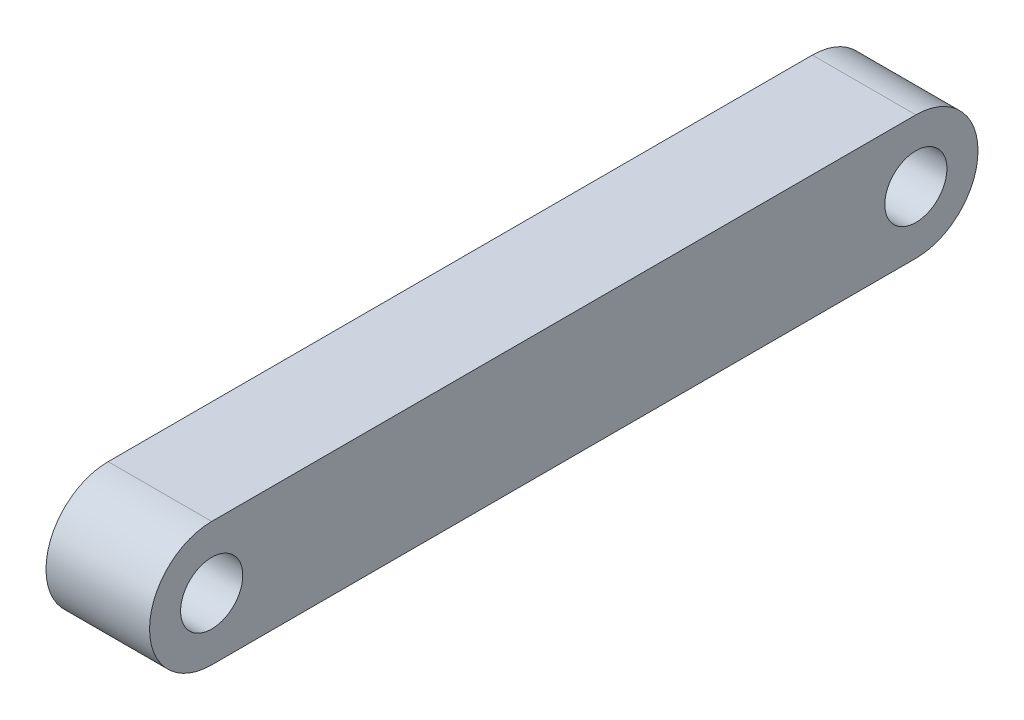
from build123d import *

# Parameters (mm, degrees)
SKETCH_1_R      = 1.5
EXTRUDE_1_DEPTH = 2.5


with BuildPart() as part:
    # 草图1 → 凸台-拉伸1 (new body, symmetric)
    with BuildSketch(Plane(origin=(0, 0, 0), x_dir=(0, 0, -1), z_dir=(1, 0, 0))):
        with BuildLine():
            Line((-17, 3), (17, 3))
            ThreePointArc((17, 3), (20, 0), (17, -3))
            Line((17, -3), (-17, -3))
            ThreePointArc((-17, -3), (-20, 0), (-17, 3))
        make_face()
        with Locations((17, 0)):
            Circle(SKETCH_1_R, mode=Mode.SUBTRACT)
        with Locations((-17, 0)):
            Circle(SKETCH_1_R, mode=Mode.SUBTRACT)
    extrude(amount=EXTRUDE_1_DEPTH, both=True)


solid = part.part
